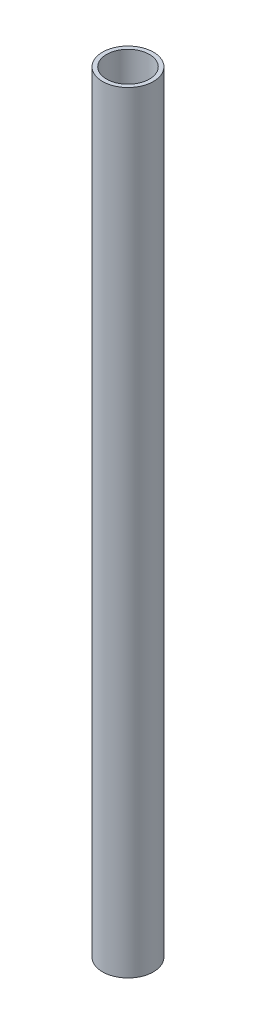
from build123d import *

# Parameters (mm, degrees)
SKETCH2_R           = 30.1625
SKETCH2_R_2         = 25.4
BOSS_EXTRUDE1_DEPTH = 914.4


with BuildPart() as part:
    # Sketch2 → Boss-Extrude1 (new body)
    with BuildSketch(Plane(origin=(0, 0, 0), x_dir=(1, 0, 0), z_dir=(0, 1, 0))):
        Circle(SKETCH2_R)
        Circle(SKETCH2_R_2, mode=Mode.SUBTRACT)
    extrude(amount=BOSS_EXTRUDE1_DEPTH)


solid = part.part
